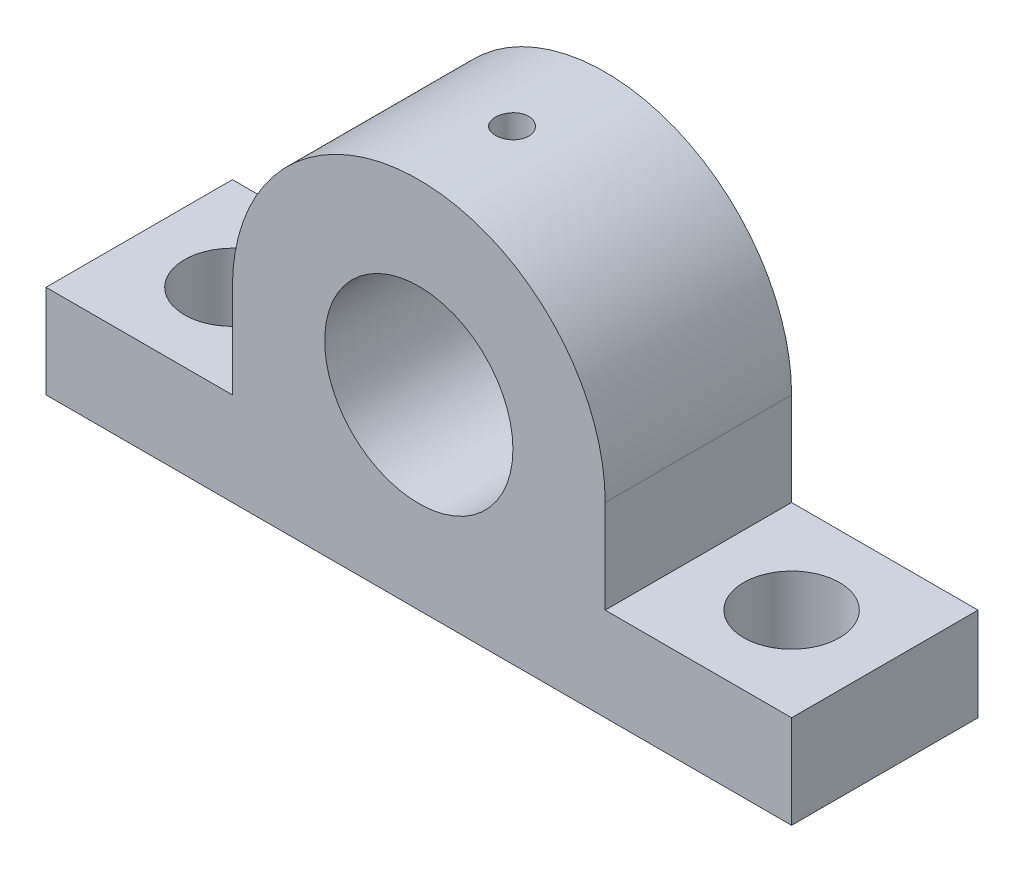
from build123d import *

# Parameters (mm, degrees)
SKETCH1_R                 = 6.4135
BOSS_EXTRUDE1_DEPTH       = 12.7
SKETCH2_R                 = 3.2639
CUT_EXTRUDE1_DEPTH        = 7.35
F_4_40_TAPPED_HOLE1_D     = 2.2606
F_4_40_TAPPED_HOLE1_DEPTH = 7.62
F_4_40_TAPPED_HOLE1_TIP   = 0.679152758


with BuildPart() as part:
    # Sketch1 → Boss-Extrude1 (new body)
    with BuildSketch(Plane.XY):
        with BuildLine():
            Line((12.7, 12.7), (12.7, 6.35))
            Line((12.7, 6.35), (25.4, 6.35))
            Line((25.4, 6.35), (25.4, 0))
            Line((25.4, 0), (-25.4, 0))
            Line((-25.4, 0), (-25.4, 6.35))
            Line((-25.4, 6.35), (-12.7, 6.35))
            Line((-12.7, 6.35), (-12.7, 12.7))
            ThreePointArc((-12.7, 12.7), (0, 25.4), (12.7, 12.7))
        make_face()
        with Locations((0, 12.7)):
            Circle(SKETCH1_R, mode=Mode.SUBTRACT)
    extrude(amount=BOSS_EXTRUDE1_DEPTH)

    # Sketch2 → Cut-Extrude1 (cut, through all)
    with BuildSketch(Plane(origin=(0, 6.35, 0), x_dir=(1, 0, 0), z_dir=(0, 1, 0))):
        with Locations((19.05, -6.35)):
            Circle(SKETCH2_R)
        with Locations((-19.05, -6.35)):
            Circle(SKETCH2_R)
    extrude(amount=-CUT_EXTRUDE1_DEPTH, mode=Mode.SUBTRACT)

    # #4-40 Tapped Hole1
    with Locations(Plane(origin=(0, 25.4, 6.35), x_dir=(1, 0, 0), z_dir=(0, 1, 0))):
        with Locations((0, 0)):
            Hole(F_4_40_TAPPED_HOLE1_D / 2, depth=F_4_40_TAPPED_HOLE1_DEPTH)
            with Locations((0, 0, -(F_4_40_TAPPED_HOLE1_DEPTH + F_4_40_TAPPED_HOLE1_TIP / 2))):  # 118° drill point
                Cone(0, F_4_40_TAPPED_HOLE1_D / 2, F_4_40_TAPPED_HOLE1_TIP, mode=Mode.SUBTRACT)


solid = part.part
